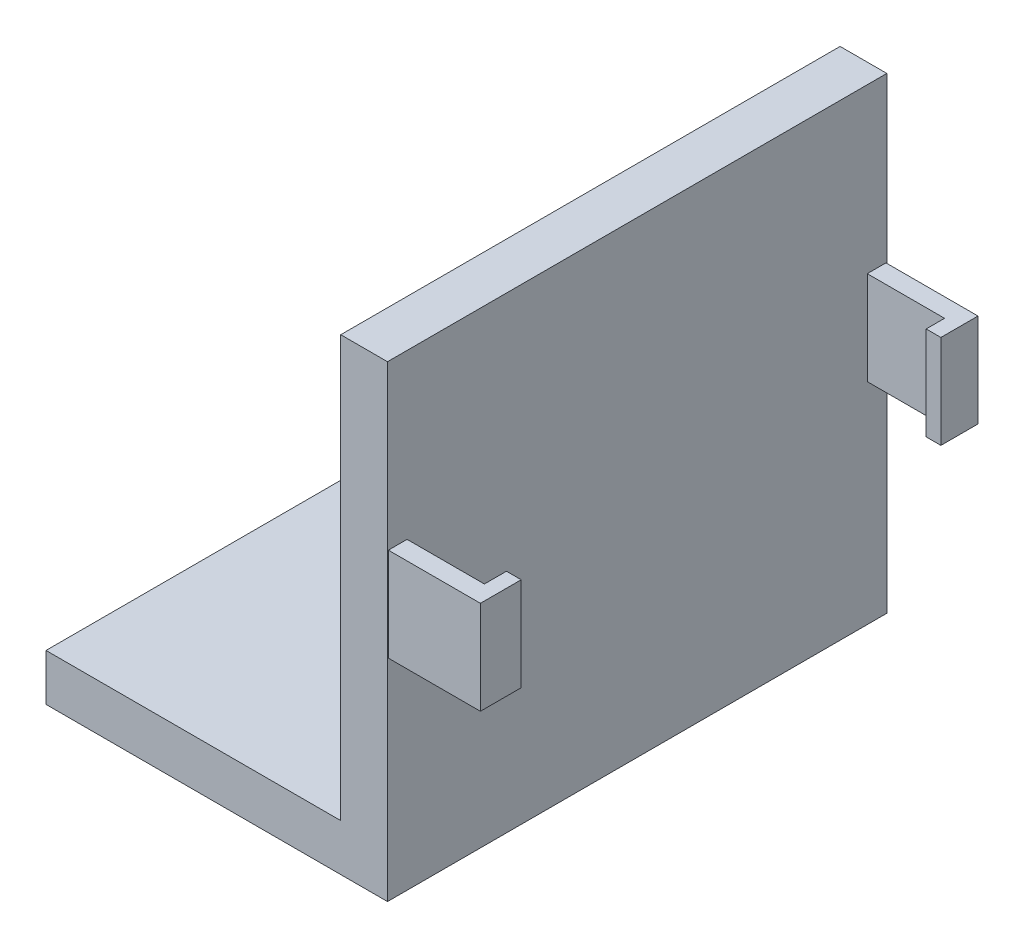
from build123d import *

# Parameters (mm, degrees)
SKETCH1_R           = 50.8
BOSS_EXTRUDE1_DEPTH = 6.35
SKETCH2_W           = 6.35
SKETCH2_H           = 67.818
BOSS_EXTRUDE2_DEPTH = 57.15
SKETCH3_W           = 2.54
SKETCH3_H           = 12.7
BOSS_EXTRUDE3_DEPTH = 12.500000082
SKETCH4_W           = 2
SKETCH4_H           = 12.7
BOSS_EXTRUDE4_DEPTH = 3
SKETCH5_W           = 2
SKETCH5_H           = 12.7
BOSS_EXTRUDE5_DEPTH = 2.5
SKETCH6_OUTSIDE_W   = 135.018
SKETCH6_OUTSIDE_H   = 135.018
SKETCH6_OUTSIDE_W_2 = 46.379926406
SKETCH6_OUTSIDE_H_2 = 67.818
CUT_EXTRUDE1_DEPTH  = 7.35


with BuildPart() as part:
    # Sketch1 → Boss-Extrude1 (new body)
    with BuildSketch(Plane(origin=(0, 0, 0), x_dir=(1, 0, 0), z_dir=(0, 1, 0))):
        Circle(SKETCH1_R)
    extrude(amount=BOSS_EXTRUDE1_DEPTH)

    # Sketch2 → Boss-Extrude2 (add)
    with BuildSketch(Plane(origin=(0, 6.35, 0), x_dir=(1, 0, 0), z_dir=(0, 1, 0))):
        with Locations((17.804926406, 0)):
            Rectangle(SKETCH2_W, SKETCH2_H)
    extrude(amount=BOSS_EXTRUDE2_DEPTH)

    # Sketch3 → Boss-Extrude3 (add)
    with BuildSketch(Plane(origin=(20.979926406, 0, 0), x_dir=(0, 0, -1), z_dir=(1, 0, 0))):
        with Locations((-32.52, 34.925)):
            Rectangle(SKETCH3_W, SKETCH3_H)
        with Locations((32.52, 34.925)):
            Rectangle(SKETCH3_W, SKETCH3_H)
    extrude(amount=BOSS_EXTRUDE3_DEPTH)

    # Sketch4 → Boss-Extrude4 (add)
    with BuildSketch(Plane(origin=(0, 0, 31.25), x_dir=(-1, 0, 0), z_dir=(0, 0, -1))):
        with Locations((-32.479926488, 34.925)):
            Rectangle(SKETCH4_W, SKETCH4_H)
    extrude(amount=BOSS_EXTRUDE4_DEPTH)

    # Sketch5 → Boss-Extrude5 (add)
    with BuildSketch(Plane.XY.offset(-31.25)):
        with Locations((32.479926488, 34.925)):
            Rectangle(SKETCH5_W, SKETCH5_H)
    extrude(amount=BOSS_EXTRUDE5_DEPTH)

    # Sketch6 outside → Cut-Extrude1 (cut, through all)
    with BuildSketch(Plane(origin=(0, 6.35, 0), x_dir=(1, 0, 0), z_dir=(0, 1, 0))):
        Rectangle(SKETCH6_OUTSIDE_W, SKETCH6_OUTSIDE_H)
        with Locations((-2.210036797, 0)):
            Rectangle(SKETCH6_OUTSIDE_W_2, SKETCH6_OUTSIDE_H_2, mode=Mode.SUBTRACT)
    extrude(amount=-CUT_EXTRUDE1_DEPTH, mode=Mode.SUBTRACT)


solid = part.part
